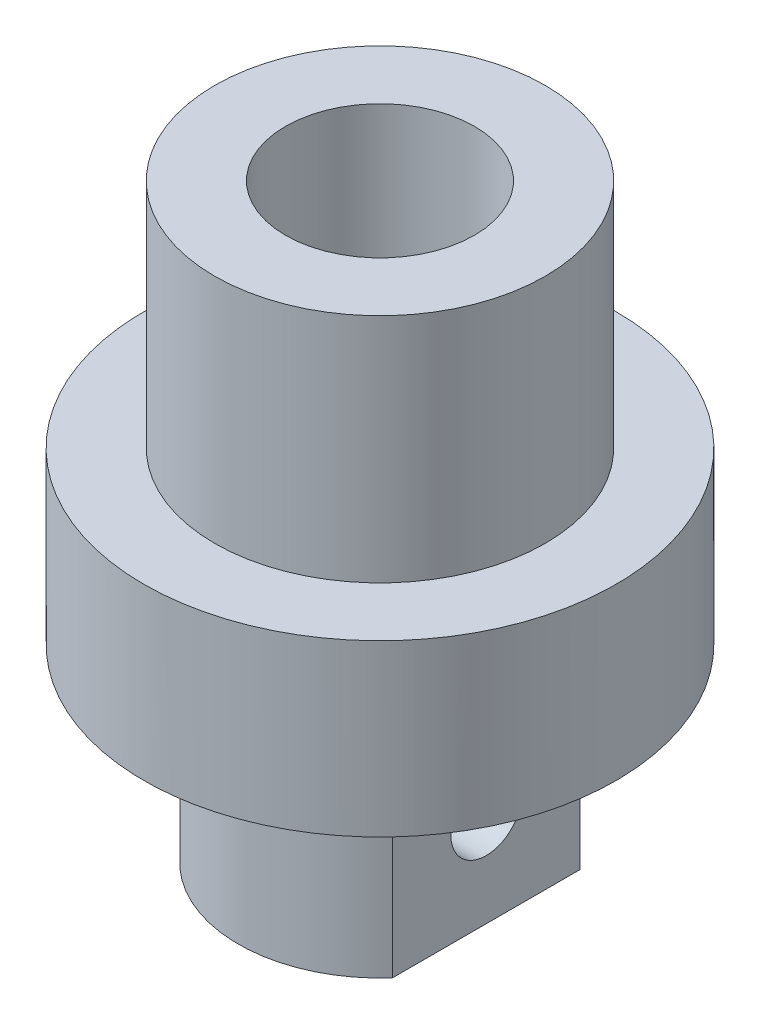
from build123d import *

# Parameters (mm, degrees)
SKETCH1_R           = 10
BOSS_EXTRUDE2_DEPTH = 25
SKETCH2_R           = 10
SKETCH2_R_2         = 7
CUT_EXTRUDE1_DEPTH  = 9.8
SKETCH3_R           = 10
SKETCH3_R_2         = 6
CUT_EXTRUDE2_DEPTH  = 8
SKETCH4_R           = 4
CUT_EXTRUDE3_DEPTH  = 15
SKETCH5_R           = 2.75
CUT_EXTRUDE4_DEPTH  = 11
CUT_EXTRUDE5_DEPTH  = 8
SKETCH7_R           = 1.5
CUT_EXTRUDE6_DEPTH  = 4


with BuildPart() as part:
    # Sketch1 → Boss-Extrude2 (new body)
    with BuildSketch(Plane(origin=(0, 0, 0), x_dir=(1, 0, 0), z_dir=(0, 1, 0))):
        Circle(SKETCH1_R)
    extrude(amount=BOSS_EXTRUDE2_DEPTH)

    # Sketch2 → Cut-Extrude1 (cut)
    with BuildSketch(Plane(origin=(0, 25, 0), x_dir=(1, 0, 0), z_dir=(0, 1, 0))):
        Circle(SKETCH2_R)
        Circle(SKETCH2_R_2, mode=Mode.SUBTRACT)
    extrude(amount=-CUT_EXTRUDE1_DEPTH, mode=Mode.SUBTRACT)

    # Sketch3 → Cut-Extrude2 (cut)
    with BuildSketch(Plane.XZ):
        Circle(SKETCH3_R)
        Circle(SKETCH3_R_2, mode=Mode.SUBTRACT)
    extrude(amount=-CUT_EXTRUDE2_DEPTH, mode=Mode.SUBTRACT)

    # Sketch4 → Cut-Extrude3 (cut)
    with BuildSketch(Plane(origin=(0, 25, 0), x_dir=(1, 0, 0), z_dir=(0, 1, 0))):
        Circle(SKETCH4_R)
    extrude(amount=-CUT_EXTRUDE3_DEPTH, mode=Mode.SUBTRACT)

    # Sketch5 → Cut-Extrude4 (cut)
    with BuildSketch(Plane.XZ):
        Circle(SKETCH5_R)
    extrude(amount=-CUT_EXTRUDE4_DEPTH, mode=Mode.SUBTRACT)

    # Sketch6 → Cut-Extrude5 (cut)
    with BuildSketch(Plane.XZ):
        with BuildLine():
            Line((4.5, 0), (4.5, 3.968626967))
            ThreePointArc((4.5, 3.968626967), (6, 0), (4.5, -3.968626967))
            Line((4.5, -3.968626967), (4.5, 0))
        make_face()
    extrude(amount=-CUT_EXTRUDE5_DEPTH, mode=Mode.SUBTRACT)

    # Sketch7 → Cut-Extrude6 (cut)
    with BuildSketch(Plane(origin=(4.5, 0, 0), x_dir=(0, 0, -1), z_dir=(1, 0, 0))):
        with Locations((0, 4)):
            Circle(SKETCH7_R)
    extrude(amount=-CUT_EXTRUDE6_DEPTH, mode=Mode.SUBTRACT)


solid = part.part
